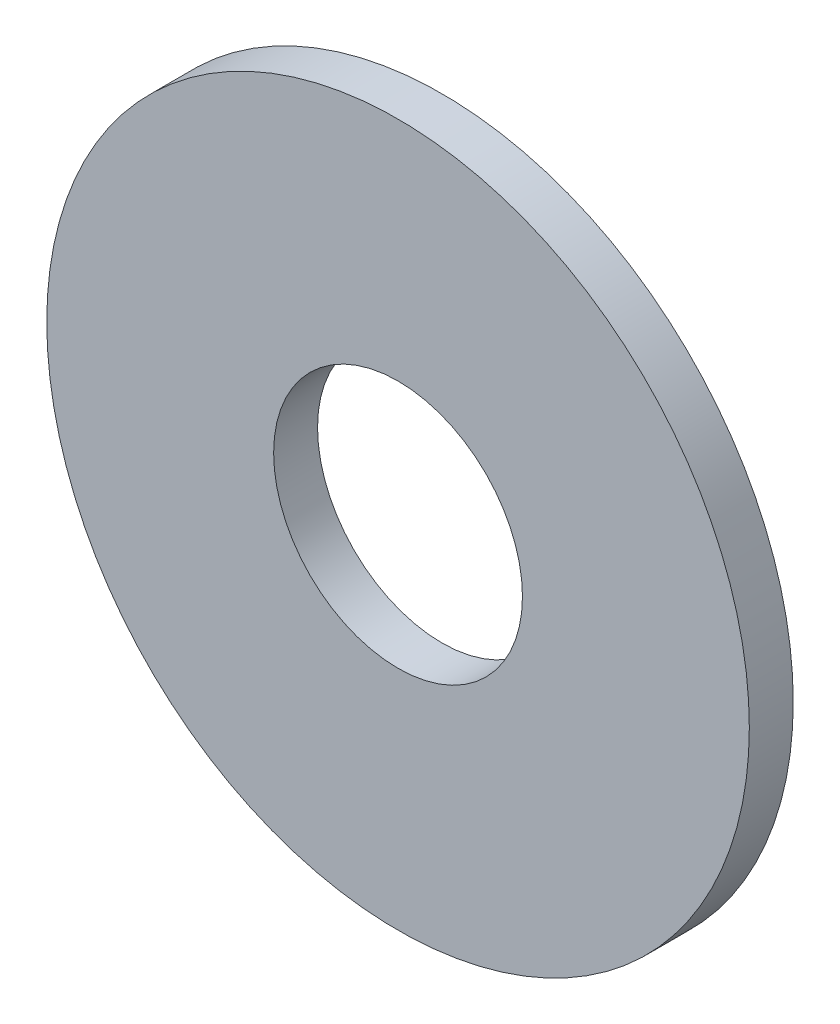
from build123d import *

# Parameters (mm, degrees)
SKETCH_1_R      = 24
SKETCH_1_R_2    = 8.5
EXTRUDE_1_DEPTH = 3


with BuildPart() as part:
    # Эскиз1 → Вытянуть1 (new body)
    with BuildSketch(Plane.XY):
        Circle(SKETCH_1_R)
        Circle(SKETCH_1_R_2, mode=Mode.SUBTRACT)
    extrude(amount=EXTRUDE_1_DEPTH)


solid = part.part
